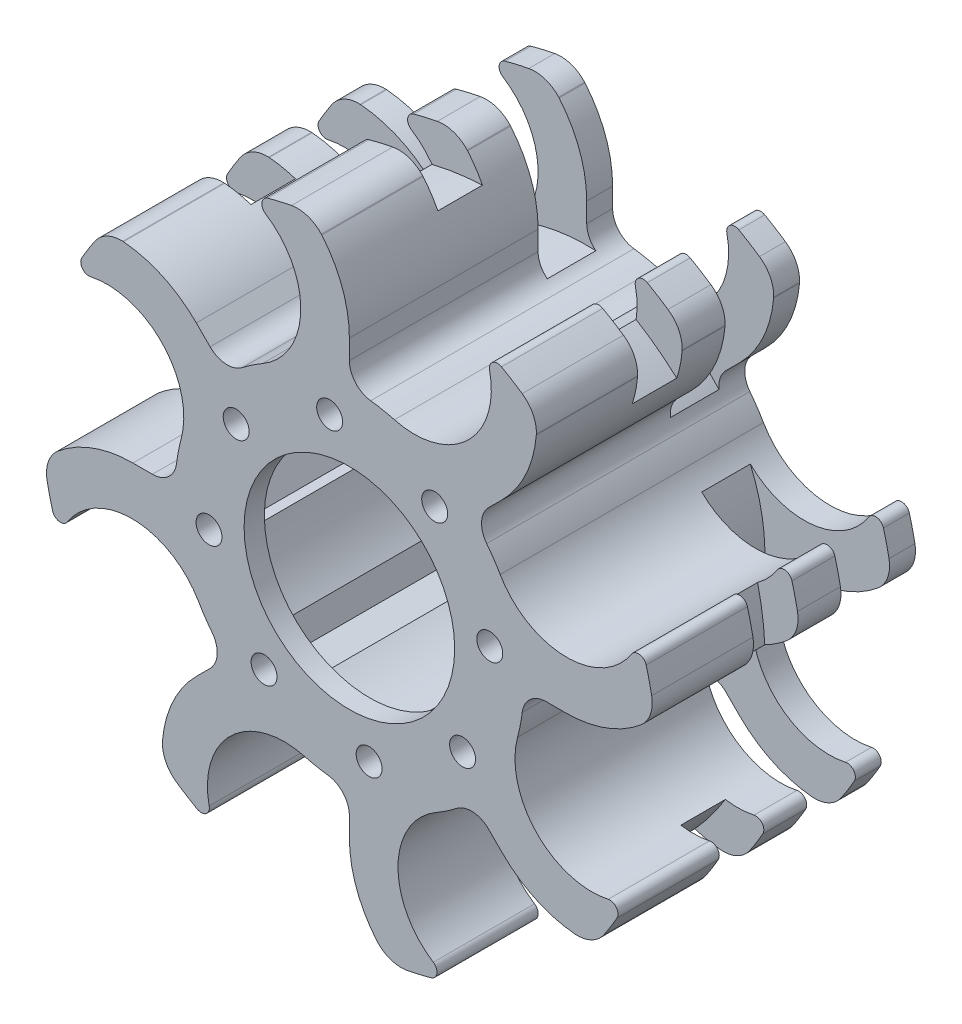
from build123d import *

# Parameters (mm, degrees)
EXTRUDE_1_DEPTH          = 32.5
PATTERN_CIRCULAR_1_COUNT = 8
FILLET_1_R               = 3
SKETCH_3_R               = 18.5
CUT_EXTRUDE_1_DEPTH      = 30
SKETCH_4_R               = 1.6
SKETCH_4_R_2             = 13
CUT_EXTRUDE_2_DEPTH      = 2.5
CUT_EXTRUDE_4_REACH      = 32
SKETCH_7_W               = 20
SKETCH_7_H               = 6
SKETCH_7_W_2             = 10
SKETCH_7_H_2             = 5.5


with BuildPart() as part:
    # 草图1 → 凸台-拉伸1 (new body)
    with BuildSketch(Plane.XY):
        with BuildLine():
            ThreePointArc((-10.356244554, 34.83376316), (-6.00280003, 26.616152007), (-10.75, 18.619546181))
            ThreePointArc((-10.75, 18.619546181), (5.56460947, -20.767405265), (0, 21.5))
            Line((0, 21.5), (0, 26.721510215))
            ThreePointArc((0, 26.721510215), (-0.876562566, 31.680090761), (-3.4, 36.037629801))
            ThreePointArc((-3.4, 36.037629801), (-3.429921119, 36.072346995), (-3.460629906, 36.106369449))
            ThreePointArc((-3.460629906, 36.106369449), (-5.148861305, 37.192002716), (-7.15188578, 37.320912767))
            ThreePointArc((-7.15188578, 37.320912767), (-8.622723673, 37.00876432), (-10.080061386, 36.638673044))
            ThreePointArc((-10.080061386, 36.638673044), (-10.803291061, 35.82575459), (-10.356244554, 34.83376316))
        make_face()
    extrude_1 = extrude(amount=EXTRUDE_1_DEPTH)

    # 阵列(圆周)1: 凸台-拉伸1 ×8 about axis
    pattern_circular_1_axis = Axis((0, 0, 0), (0, 0, 1))
    for i in range(1, PATTERN_CIRCULAR_1_COUNT):
        add(extrude_1.rotate(pattern_circular_1_axis, i * 360 / PATTERN_CIRCULAR_1_COUNT))

    # 圆角1
    fillet_1_edges = [part.edges().sort_by_distance(p)[0] for p in [
        (0, 21.5, 16.25),
        (-15.202795796, 15.202795796, 16.25),
        (-15.202795796, -15.202795796, 16.25),
        (15.202795796, -15.202795796, 16.25),
        (15.202795796, 15.202795796, 16.25),
        (21.5, 0, 16.25),
        (0, -21.5, 16.25),
        (-21.5, 0, 16.25),
    ]]
    fillet(fillet_1_edges, radius=FILLET_1_R)

    # 草图3 → 切除-拉伸1 (cut)
    with BuildSketch(Plane(origin=(0, 0, 0), x_dir=(-1, 0, 0), z_dir=(0, 0, -1))):
        Circle(SKETCH_3_R)
    extrude(amount=-CUT_EXTRUDE_1_DEPTH, mode=Mode.SUBTRACT)

    # 草图4 → 切除-拉伸2 (cut)
    with BuildSketch(Plane.XY.offset(32.5)):
        with Locations((-2.435529267, 17.329691203)):
            Circle(SKETCH_4_R)
        Circle(SKETCH_4_R_2)
        with Locations((10.531762905, 13.976121426)):
            Circle(SKETCH_4_R)
        with Locations((17.329691203, 2.435529267)):
            Circle(SKETCH_4_R)
        with Locations((13.976121426, -10.531762905)):
            Circle(SKETCH_4_R)
        with Locations((2.435529267, -17.329691203)):
            Circle(SKETCH_4_R)
        with Locations((-10.531762905, -13.976121426)):
            Circle(SKETCH_4_R)
        with Locations((-17.329691203, -2.435529267)):
            Circle(SKETCH_4_R)
        with Locations((-13.976121426, 10.531762905)):
            Circle(SKETCH_4_R)
    extrude(amount=-CUT_EXTRUDE_2_DEPTH, mode=Mode.SUBTRACT)

    # 草图6 → 切除-拉伸4 (cut, up to next)
    with BuildSketch(Plane(origin=(0, 0, 30), x_dir=(-1, 0, 0), z_dir=(0, 0, -1)), mode=Mode.PRIVATE) as cut_extrude_4_sk1:
        Polygon((2.435529267, 20.620587737), (-0.414470733, 18.97513947), (-0.414470733, 15.684242936), (2.435529267, 14.038794669), (5.285529267, 15.684242936), (5.285529267, 18.97513947), align=None)
    cut_extrude_4_tool1 = extrude(cut_extrude_4_sk1.sketch, amount=CUT_EXTRUDE_4_REACH, mode=Mode.PRIVATE) & part.part
    add(cut_extrude_4_tool1.solids().sort_by_distance((-2.435529, 17.329691, 30))[0], mode=Mode.SUBTRACT)
    # 草图6 → 切除-拉伸4 (cut, up to next)
    with BuildSketch(Plane(origin=(0, 0, 30), x_dir=(-1, 0, 0), z_dir=(0, 0, -1)), mode=Mode.PRIVATE) as cut_extrude_4_sk2:
        Polygon((16.303136681, 12.858778161), (13.124374727, 13.710524859), (10.797359472, 11.383509604), (11.64910617, 8.20474765), (14.827868124, 7.353000951), (17.15488338, 9.680016207), align=None)
    cut_extrude_4_tool2 = extrude(cut_extrude_4_sk2.sketch, amount=CUT_EXTRUDE_4_REACH, mode=Mode.PRIVATE) & part.part
    add(cut_extrude_4_tool2.solids().sort_by_distance((-13.976121, 10.531763, 30))[0], mode=Mode.SUBTRACT)
    # 草图6 → 切除-拉伸4 (cut, up to next)
    with BuildSketch(Plane(origin=(0, 0, 30), x_dir=(-1, 0, 0), z_dir=(0, 0, -1)), mode=Mode.PRIVATE) as cut_extrude_4_sk3:
        Polygon((20.620587737, -2.435529267), (18.97513947, 0.414470733), (15.684242936, 0.414470733), (14.038794669, -2.435529267), (15.684242936, -5.285529267), (18.97513947, -5.285529267), align=None)
    cut_extrude_4_tool3 = extrude(cut_extrude_4_sk3.sketch, amount=CUT_EXTRUDE_4_REACH, mode=Mode.PRIVATE) & part.part
    add(cut_extrude_4_tool3.solids().sort_by_distance((-17.329691, -2.435529, 30))[0], mode=Mode.SUBTRACT)
    # 草图6 → 切除-拉伸4 (cut, up to next)
    with BuildSketch(Plane(origin=(0, 0, 30), x_dir=(-1, 0, 0), z_dir=(0, 0, -1)), mode=Mode.PRIVATE) as cut_extrude_4_sk4:
        Polygon((12.858778161, -16.303136681), (13.710524859, -13.124374727), (11.383509604, -10.797359472), (8.20474765, -11.64910617), (7.353000951, -14.827868124), (9.680016207, -17.15488338), align=None)
    cut_extrude_4_tool4 = extrude(cut_extrude_4_sk4.sketch, amount=CUT_EXTRUDE_4_REACH, mode=Mode.PRIVATE) & part.part
    add(cut_extrude_4_tool4.solids().sort_by_distance((-10.531763, -13.976121, 30))[0], mode=Mode.SUBTRACT)
    # 草图6 → 切除-拉伸4 (cut, up to next)
    with BuildSketch(Plane(origin=(0, 0, 30), x_dir=(-1, 0, 0), z_dir=(0, 0, -1)), mode=Mode.PRIVATE) as cut_extrude_4_sk5:
        Polygon((-2.435529267, -20.620587737), (0.414470733, -18.97513947), (0.414470733, -15.684242936), (-2.435529267, -14.038794669), (-5.285529267, -15.684242936), (-5.285529267, -18.97513947), align=None)
    cut_extrude_4_tool5 = extrude(cut_extrude_4_sk5.sketch, amount=CUT_EXTRUDE_4_REACH, mode=Mode.PRIVATE) & part.part
    add(cut_extrude_4_tool5.solids().sort_by_distance((2.435529, -17.329691, 30))[0], mode=Mode.SUBTRACT)
    # 草图6 → 切除-拉伸4 (cut, up to next)
    with BuildSketch(Plane(origin=(0, 0, 30), x_dir=(-1, 0, 0), z_dir=(0, 0, -1)), mode=Mode.PRIVATE) as cut_extrude_4_sk6:
        Polygon((-16.303136681, -12.858778161), (-13.124374727, -13.710524859), (-10.797359472, -11.383509604), (-11.64910617, -8.20474765), (-14.827868124, -7.353000951), (-17.15488338, -9.680016207), align=None)
    cut_extrude_4_tool6 = extrude(cut_extrude_4_sk6.sketch, amount=CUT_EXTRUDE_4_REACH, mode=Mode.PRIVATE) & part.part
    add(cut_extrude_4_tool6.solids().sort_by_distance((13.976121, -10.531763, 30))[0], mode=Mode.SUBTRACT)
    # 草图6 → 切除-拉伸4 (cut, up to next)
    with BuildSketch(Plane(origin=(0, 0, 30), x_dir=(-1, 0, 0), z_dir=(0, 0, -1)), mode=Mode.PRIVATE) as cut_extrude_4_sk7:
        Polygon((-20.620587737, 2.435529267), (-18.97513947, -0.414470733), (-15.684242936, -0.414470733), (-14.038794669, 2.435529267), (-15.684242936, 5.285529267), (-18.97513947, 5.285529267), align=None)
    cut_extrude_4_tool7 = extrude(cut_extrude_4_sk7.sketch, amount=CUT_EXTRUDE_4_REACH, mode=Mode.PRIVATE) & part.part
    add(cut_extrude_4_tool7.solids().sort_by_distance((17.329691, 2.435529, 30))[0], mode=Mode.SUBTRACT)
    # 草图6 → 切除-拉伸4 (cut, up to next)
    with BuildSketch(Plane(origin=(0, 0, 30), x_dir=(-1, 0, 0), z_dir=(0, 0, -1)), mode=Mode.PRIVATE) as cut_extrude_4_sk8:
        Polygon((-12.858778161, 16.303136681), (-13.710524859, 13.124374727), (-11.383509604, 10.797359472), (-8.20474765, 11.64910617), (-7.353000951, 14.827868124), (-9.680016207, 17.15488338), align=None)
    cut_extrude_4_tool8 = extrude(cut_extrude_4_sk8.sketch, amount=CUT_EXTRUDE_4_REACH, mode=Mode.PRIVATE) & part.part
    add(cut_extrude_4_tool8.solids().sort_by_distance((10.531763, 13.976121, 30))[0], mode=Mode.SUBTRACT)

    # 草图7 → 切除-旋转1 (revolve, cut)
    with BuildSketch(Plane(origin=(0, 0, 0), x_dir=(1, 0, 0), z_dir=(0, 1, 0))):
        with Locations((32, -6.2)):
            Rectangle(SKETCH_7_W, SKETCH_7_H)
        with Locations((38.320912767, -17.25)):
            Rectangle(SKETCH_7_W_2, SKETCH_7_H_2)
    revolve(axis=Axis((0, 0, 0), (0, 0, -1)), mode=Mode.SUBTRACT)


solid = part.part
